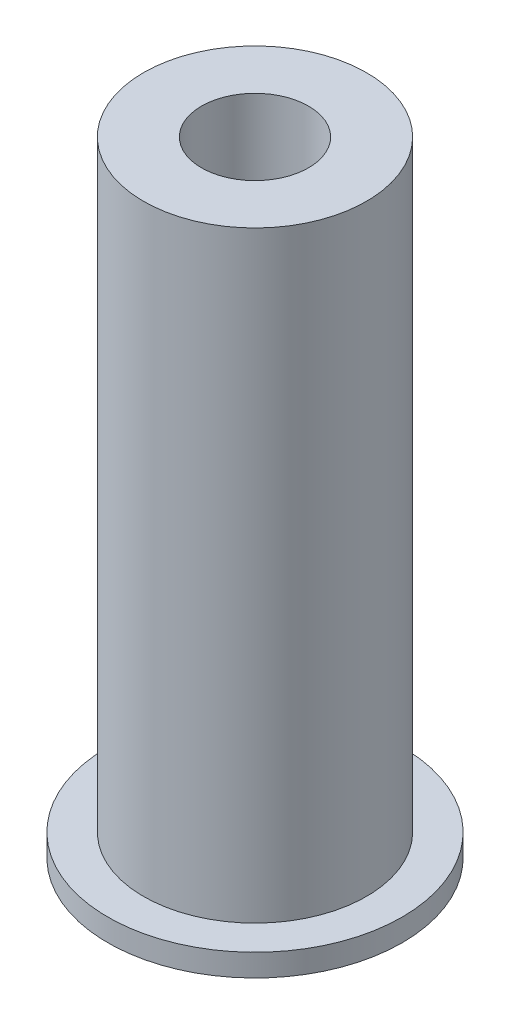
from build123d import *


with BuildPart() as part:
    # Sketch1 → Revolve1 (revolve)
    with BuildSketch(Plane.XY):
        Polygon((-5, -17), (-5, -35), (-8.25, -35), (-8.25, -33.75), (-6.25, -33.75), (-6.25, 0), (-3, 0), (-3, -17), align=None)
    revolve(axis=Axis((0, 0, 0), (0, -1, 0)))


solid = part.part
